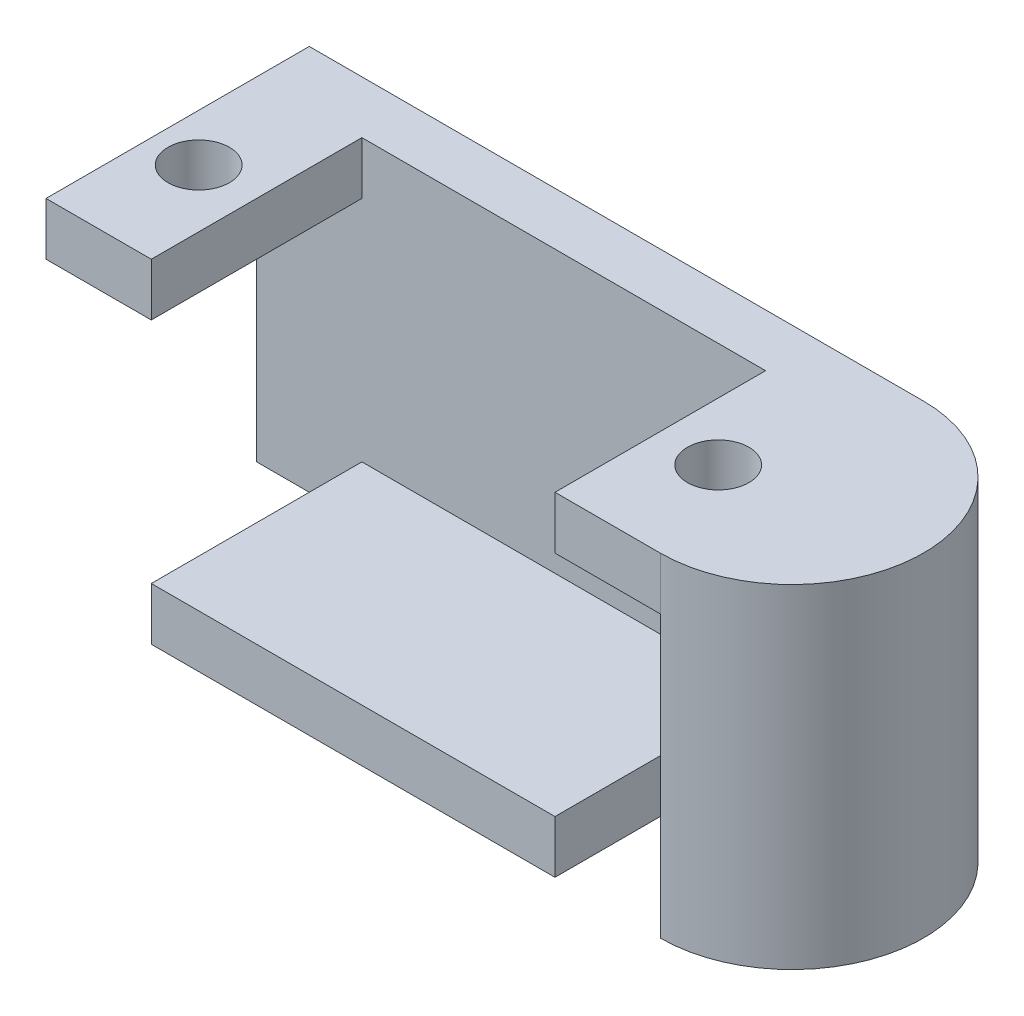
from build123d import *

# Parameters (mm, degrees)
BOSS_EXTRU_1_DEPTH      = 19
ENL_V_MAT_EXTRU_2_DEPTH = 12
ESQUISSE4_R             = 1.75
ENL_V_MAT_EXTRU_3_DEPTH = 12
ESQUISSE5_R             = 1.25
BOSS_EXTRU_2_DEPTH      = 3


with BuildPart() as part:
    # Esquisse1 → Boss.-Extru.1 (new body)
    with BuildSketch(Plane(origin=(0, 0, 0), x_dir=(1, 0, 0), z_dir=(0, 1, 0))):
        with BuildLine():
            Line((0, 0), (35, 0))
            ThreePointArc((35, 0), (42.5, 7.5), (35, 15))
            Line((35, 15), (0, 15))
            Line((0, 15), (0, 0))
        make_face()
    extrude(amount=BOSS_EXTRU_1_DEPTH)

    # Esquisse3 → Enlèv. mat.-Extru.2 (cut)
    with BuildSketch(Plane.XY):
        Polygon((6, 19), (29, 19), (29, 16), (35, 16), (35, 3.144779012), (35, 0), (29, 0), (29, 3), (6, 3), (6, 0), (0, 0), (0, 3.824764885), (0, 16), (6, 16), align=None)
    extrude(amount=-ENL_V_MAT_EXTRU_2_DEPTH, mode=Mode.SUBTRACT)

    # Esquisse4 → Enlèv. mat.-Extru.3 (cut)
    with BuildSketch(Plane(origin=(0, 19, 0), x_dir=(1, 0, 0), z_dir=(0, 1, 0))):
        with Locations((2.7, 6)):
            Circle(ESQUISSE4_R)
        with Locations((32.3, 6)):
            Circle(ESQUISSE4_R)
    extrude(amount=-ENL_V_MAT_EXTRU_3_DEPTH, mode=Mode.SUBTRACT)

    # Esquisse5 → Boss.-Extru.2 (add)
    with BuildSketch(Plane.XZ):
        with Locations((12, -6)):
            Circle(ESQUISSE5_R)
    extrude(amount=BOSS_EXTRU_2_DEPTH)


solid = part.part
